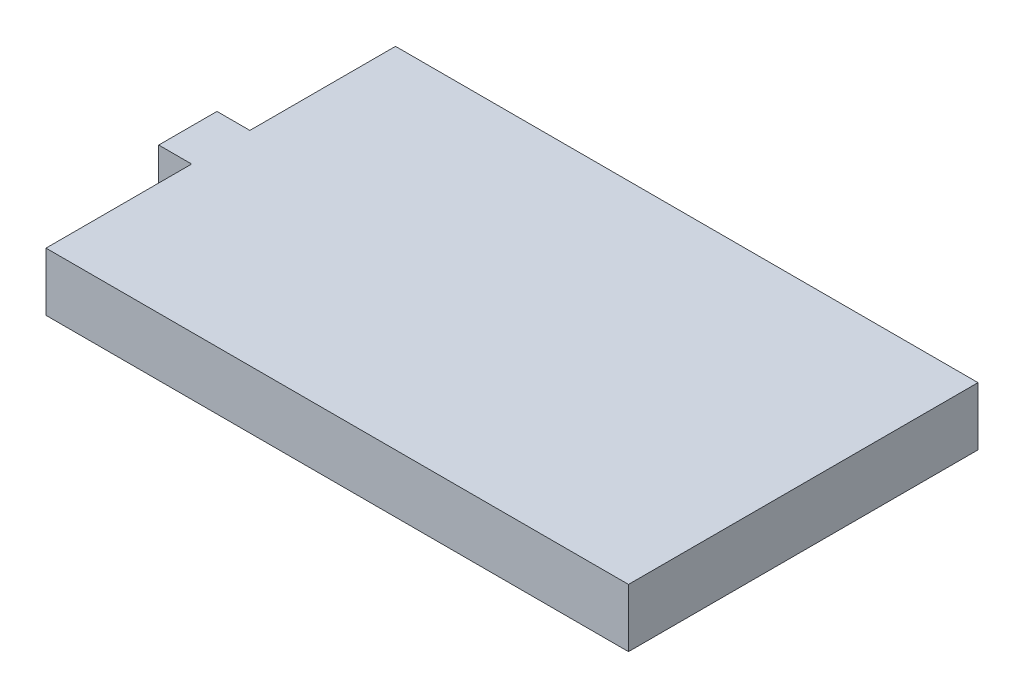
from build123d import *

# Parameters (mm, degrees)
BOSS_EXTRUDE1_DEPTH = 6.35


with BuildPart() as part:
    # Sketch1 → Boss-Extrude1 (new body)
    with BuildSketch(Plane(origin=(0, 0, 0), x_dir=(1, 0, 0), z_dir=(0, 1, 0))):
        Polygon((-31.75, 3.175), (-31.75, 19.05), (31.75, 19.05), (31.75, -19.05), (-31.75, -19.05), (-31.75, -3.175), (-35.337876689, -3.175), (-35.337876689, 3.175), align=None)
    extrude(amount=BOSS_EXTRUDE1_DEPTH)


solid = part.part
